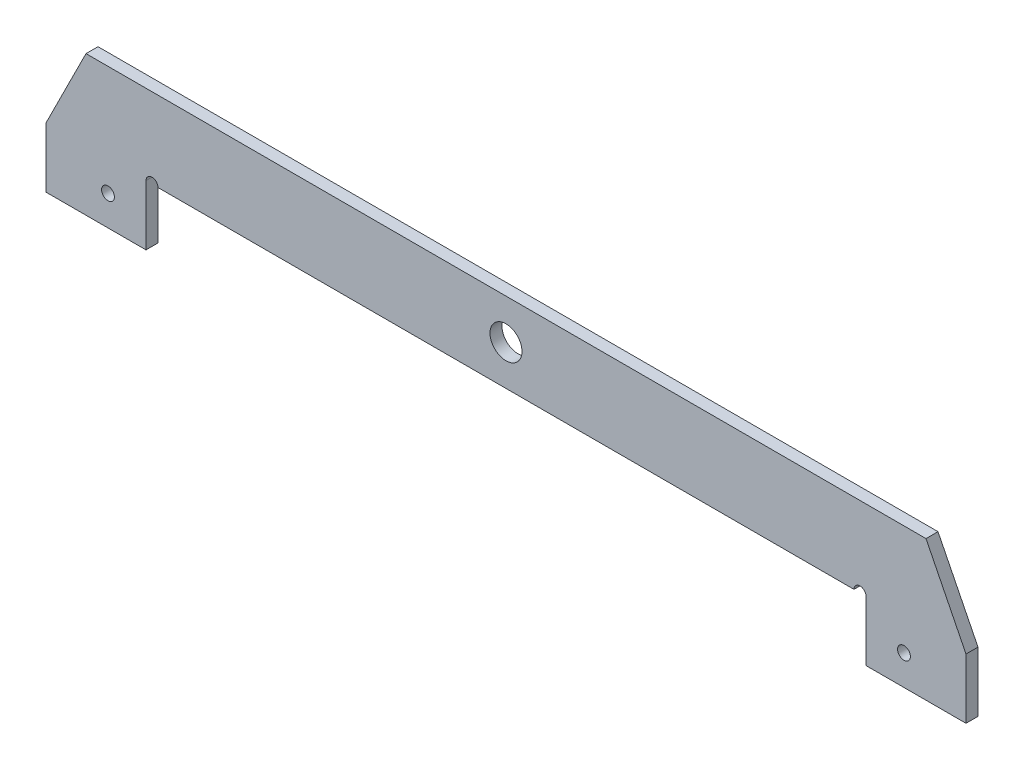
from build123d import *

# Parameters (mm, degrees)
SKETCH_1_R          = 4
EXTRUDE_1_DEPTH     = 3
SKETCH_2_R          = 1.5
CUT_EXTRUDE_1_DEPTH = 4
EXTRUDE_2_DEPTH     = 3
CUT_EXTRUDE_2_REACH = 5
SKETCH_4_R          = 1.6


with BuildPart() as part:
    # 草图1 → 凸台-拉伸1 (new body)
    with BuildSketch(Plane.XY):
        Polygon((90, 0), (-90, 0), (-90, -15), (-115, -15), (-115, 0), (-105, 0), (-105, 20), (105, 20), (105, 0), (115, 0), (115, -15), (90, -15), align=None)
        with Locations((0, 10)):
            Circle(SKETCH_1_R, mode=Mode.SUBTRACT)
    extrude(amount=EXTRUDE_1_DEPTH)

    # 草图2 → 切除-拉伸1 (cut, through all)
    with BuildSketch(Plane.XY.offset(3)):
        with Locations((-88.5, 0)):
            Circle(SKETCH_2_R)
        with Locations((88.5, 0)):
            Circle(SKETCH_2_R)
    extrude(amount=-CUT_EXTRUDE_1_DEPTH, mode=Mode.SUBTRACT)

    # 草图3 → 凸台-拉伸2 (add)
    with BuildSketch(Plane.XY.offset(3)):
        Polygon((-115, 0), (-105, 20), (-105, 0), align=None)
        Polygon((105, 20), (105, 0), (115, 0), align=None)
    extrude(amount=-EXTRUDE_2_DEPTH)

    # 草图4 → 切除-拉伸2 (cut, up to next)
    with BuildSketch(Plane.XY.offset(3), mode=Mode.PRIVATE) as cut_extrude_2_sk1:
        with Locations((-99.5, -7.5)):
            Circle(SKETCH_4_R)
    cut_extrude_2_tool1 = extrude(cut_extrude_2_sk1.sketch, amount=-CUT_EXTRUDE_2_REACH, mode=Mode.PRIVATE) & part.part
    add(cut_extrude_2_tool1.solids().sort_by_distance((-99.5, -7.5, 3))[0], mode=Mode.SUBTRACT)
    # 草图4 → 切除-拉伸2 (cut, up to next)
    with BuildSketch(Plane.XY.offset(3), mode=Mode.PRIVATE) as cut_extrude_2_sk2:
        with Locations((99.5, -7.5)):
            Circle(SKETCH_4_R)
    cut_extrude_2_tool2 = extrude(cut_extrude_2_sk2.sketch, amount=-CUT_EXTRUDE_2_REACH, mode=Mode.PRIVATE) & part.part
    add(cut_extrude_2_tool2.solids().sort_by_distance((99.5, -7.5, 3))[0], mode=Mode.SUBTRACT)


solid = part.part
